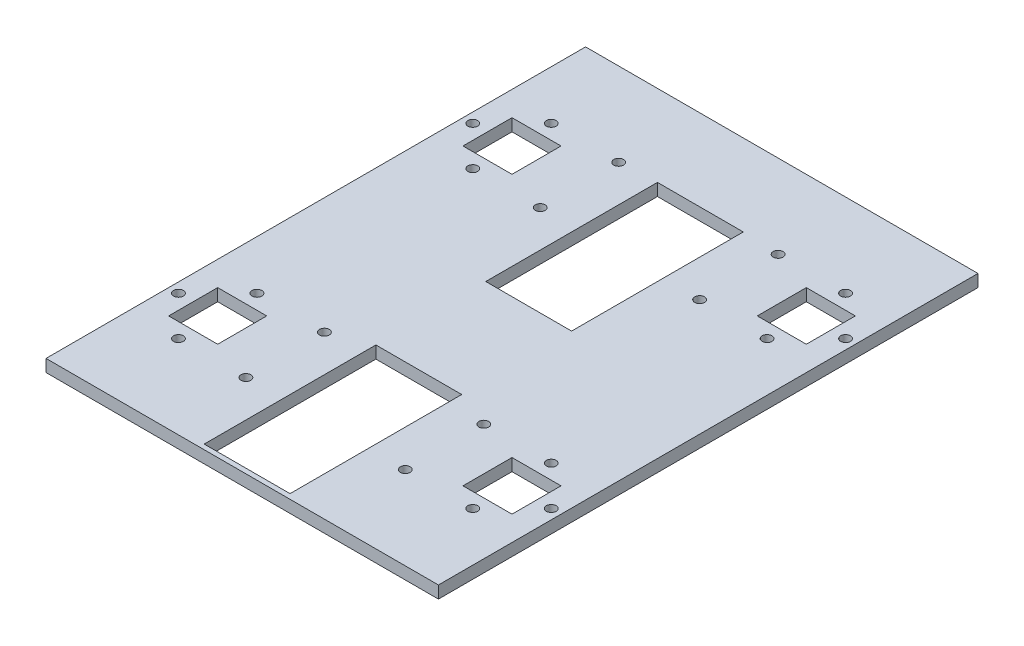
from build123d import *

# Parameters (mm, degrees)
SKETCH1_W               = 203.2
SKETCH1_H               = 279.4
BOSS_EXTRUDE1_DEPTH     = 6.35
CUT_EXTRUDE1_START      = -7.35
SKETCH2_R               = 2.54
SKETCH2_W               = 25.4
SKETCH2_H               = 25.4
CUT_EXTRUDE1_DEPTH      = 8.35
MIRROR2_START           = -7.35
MIRROR2_COPY_1_SKETCH_R = 2.54
MIRROR2_COPY_1_SKETCH_W = 25.4
MIRROR2_COPY_1_SKETCH_H = 25.4
MIRROR2_COPY_1_DEPTH    = 8.35
SKETCH3_W               = 88.9
SKETCH3_H               = 44.45
CUT_EXTRUDE2_DEPTH      = 1
CUT_EXTRUDE2_DEPTH_BACK = 7.35


with BuildPart() as part:
    # Sketch1 → Boss-Extrude1 (new body)
    with BuildSketch(Plane(origin=(0, 0, 0), x_dir=(1, 0, 0), z_dir=(0, 1, 0))):
        Rectangle(SKETCH1_W, SKETCH1_H)
    extrude(amount=BOSS_EXTRUDE1_DEPTH)

    # Sketch2 → Cut-Extrude1 (cut)
    with BuildSketch(Plane(origin=(0, 6.35, 0), x_dir=(1, 0, 0), z_dir=(0, 1, 0)).offset(CUT_EXTRUDE1_START)):
        with Locations((-41.275, 55.88)):
            Circle(SKETCH2_R)
        with Locations((-41.275, 96.52)):
            Circle(SKETCH2_R)
        with Locations((-76.2, 55.88)):
            Circle(SKETCH2_R)
        with Locations((-96.52, 76.2)):
            Circle(SKETCH2_R)
        with Locations((-76.2, 96.52)):
            Circle(SKETCH2_R)
        with Locations((-76.2, 76.2)):
            Rectangle(SKETCH2_W, SKETCH2_H)
    cut_extrude1 = extrude(amount=CUT_EXTRUDE1_DEPTH, mode=Mode.SUBTRACT)

    # Mirror1: Cut-Extrude1 across plane
    add(cut_extrude1.mirror(Plane.XY), mode=Mode.SUBTRACT)

    # Mirror2: Cut-Extrude1 across plane
    add(cut_extrude1.mirror(Plane(origin=(0, 0, 0), x_dir=(0, 0, 1), z_dir=(1, 0, 0))), mode=Mode.SUBTRACT)

    # Mirror2 copy 1 sketch → Mirror2 copy 1 (cut)
    with BuildSketch(Plane(origin=(0, 6.35, 0), x_dir=(-1, 0, 0), z_dir=(0, 1, 0)).offset(MIRROR2_START)):
        with Locations((-41.275, 55.88)):
            Circle(MIRROR2_COPY_1_SKETCH_R)
        with Locations((-41.275, 96.52)):
            Circle(MIRROR2_COPY_1_SKETCH_R)
        with Locations((-76.2, 55.88)):
            Circle(MIRROR2_COPY_1_SKETCH_R)
        with Locations((-96.52, 76.2)):
            Circle(MIRROR2_COPY_1_SKETCH_R)
        with Locations((-76.2, 96.52)):
            Circle(MIRROR2_COPY_1_SKETCH_R)
        with Locations((-76.2, 76.2)):
            Rectangle(MIRROR2_COPY_1_SKETCH_W, MIRROR2_COPY_1_SKETCH_H)
    extrude(amount=MIRROR2_COPY_1_DEPTH, mode=Mode.SUBTRACT)

    # Sketch3 → Cut-Extrude2 (cut, two sides)
    with BuildSketch(Plane(origin=(32.763599602, 6.35, -4.611240895), x_dir=(0, 0, 1), z_dir=(0, 1, 0))) as cut_extrude2_sk:
        with Locations((-48.474759105, -32.763599602)):
            Rectangle(SKETCH3_W, SKETCH3_H)
        with Locations((97.321240895, -32.763599602)):
            Rectangle(SKETCH3_W, SKETCH3_H)
    extrude(amount=CUT_EXTRUDE2_DEPTH, mode=Mode.SUBTRACT)
    extrude(cut_extrude2_sk.sketch, amount=-CUT_EXTRUDE2_DEPTH_BACK, mode=Mode.SUBTRACT)


solid = part.part
